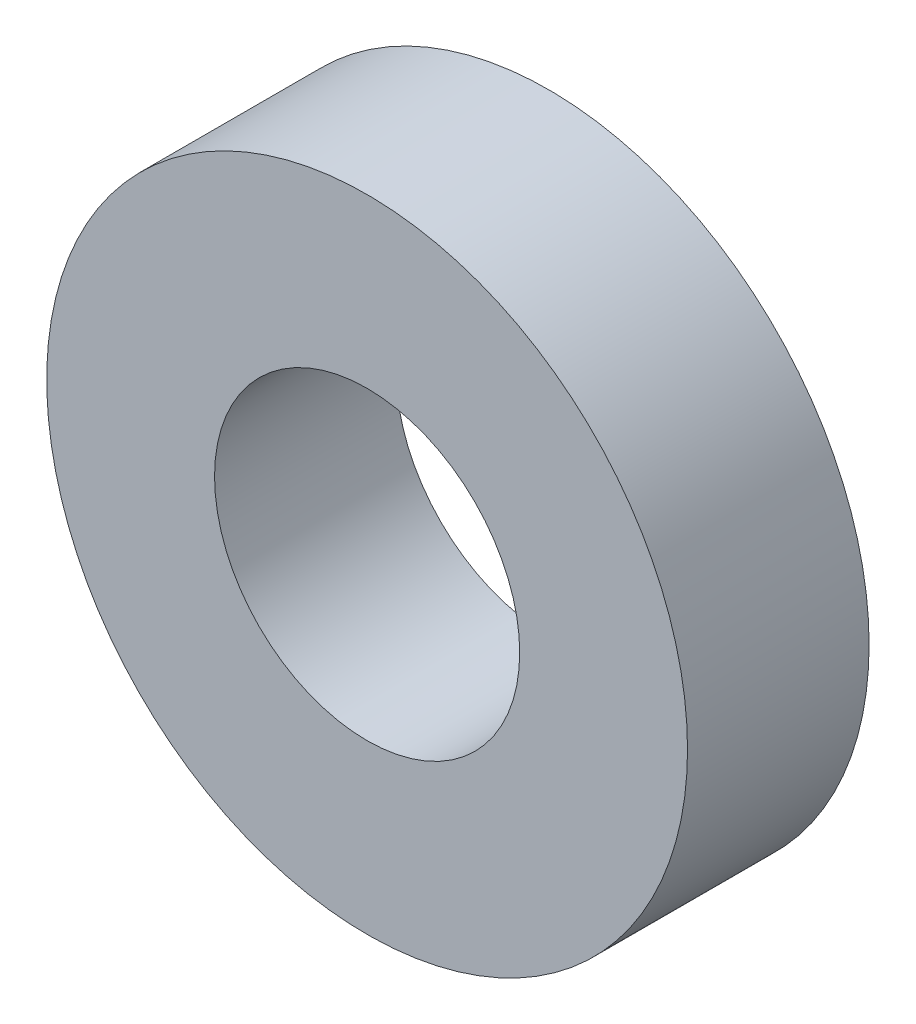
from build123d import *

# Parameters (mm, degrees)
CROQUIS1_R              = 21
CROQUIS1_R_2            = 10
SALIENTE_EXTRUIR1_DEPTH = 11.9


with BuildPart() as part:
    # Croquis1 → Saliente-Extruir1 (new body)
    with BuildSketch(Plane.XY):
        Circle(CROQUIS1_R)
        Circle(CROQUIS1_R_2, mode=Mode.SUBTRACT)
    extrude(amount=SALIENTE_EXTRUIR1_DEPTH)


solid = part.part
